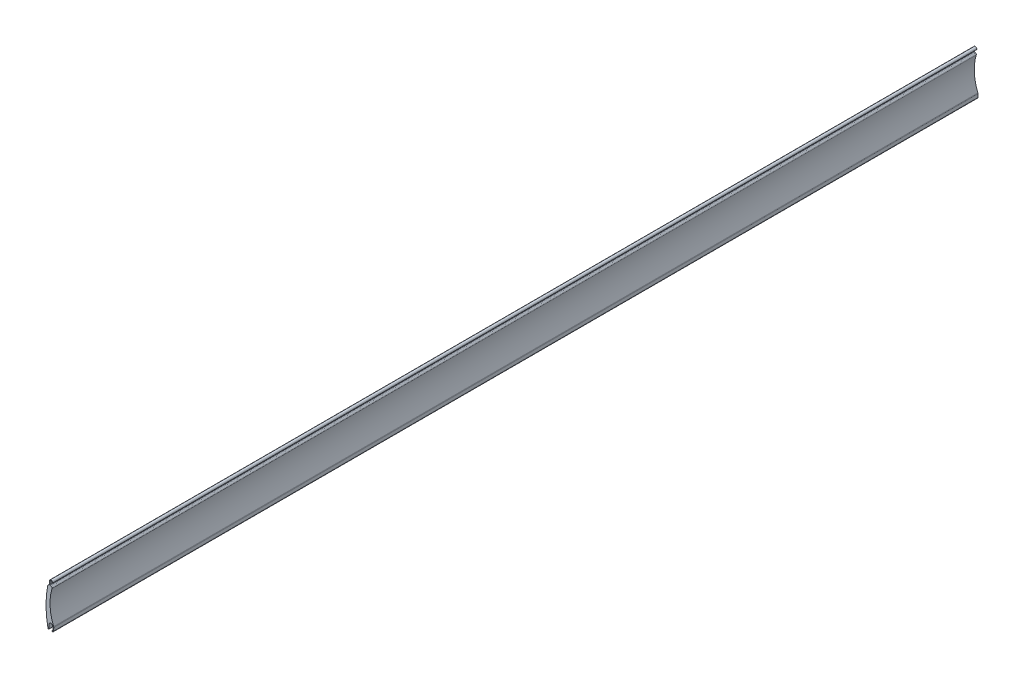
from build123d import *

# Parameters (mm, degrees)
BODY_DEPTH                      = 885
SCHNITT_LINEAR_AUSTRAGEN2_DEPTH = 885


with BuildPart() as part:
    # Model → Body (new body)
    with BuildSketch(Plane.XY):
        with BuildLine():
            Line((1.878084628, 39.104629182), (2.149753631, 39.265339178))
            ThreePointArc((2.149753631, 39.265339178), (1.179756728, 40.293308137), (0.151359725, 39.323765061))
            Line((0.151359725, 39.323765061), (0.072230593, 36.617684207))
            ThreePointArc((0.072230593, 36.617684207), (0.185489498, 36.248958877), (0.499809768, 36.025377312))
            Line((0.499809768, 36.025377312), (1.261518581, 35.79721719))
            ThreePointArc((1.261518581, 35.79721719), (2.002767255, 35.193636824), (2.100773109, 34.24276685))
            ThreePointArc((2.100773109, 34.24276685), (0.243973004, 18.756791477), (3.6673456, 3.540232734))
            ThreePointArc((3.6673456, 3.540232734), (3.762278433, 3.217871116), (3.78778584, 2.882791084))
            Line((3.78778584, 2.882791084), (3.698637797, -0.165904914))
            ThreePointArc((3.698637797, -0.165904914), (3.256166133, -1.000710488), (2.324510635, -1.157871399))
            Line((2.324510635, -1.157871399), (2.175621232, -1.113273313))
            ThreePointArc((2.175621232, -1.113273313), (1.997498531, -0.968129525), (1.974178859, -0.739545604))
            Line((1.974178859, -0.739545604), (0.400869285, -0.26828127))
            Line((0.400869285, -0.26828127), (-0.708129005, -0.492759369))
            ThreePointArc((-0.708129005, -0.492759369), (-1.196616048, -1.010909594), (-1.76840947, -0.586466985))
            ThreePointArc((-1.76840947, -0.586466985), (-3.655039198, 17.174334722), (-1.986171677, 34.956919747))
            ThreePointArc((-1.986171677, 34.956919747), (-1.847587365, 35.23826116), (-1.585988155, 35.411248024))
            Line((-1.585988155, 35.411248024), (-1.044699422, 35.590524224))
            ThreePointArc((-1.044699422, 35.590524224), (-0.684484453, 35.850559404), (-0.538564027, 36.270178693))
            Line((-0.538564027, 36.270178693), (-0.448759368, 39.341314215))
            ThreePointArc((-0.448759368, 39.341314215), (1.197302045, 40.893129938), (2.749873366, 39.247781189))
            ThreePointArc((2.749873366, 39.247781189), (2.372981432, 38.816883238), (1.878084628, 39.104629182))
        make_face()
    extrude(amount=-BODY_DEPTH)

    # Skizze3 → Schnitt-Linear austragen2 (cut)
    with BuildSketch(Plane.XY):
        with BuildLine():
            Line((-0.588130108, 3.611006063), (-0.708129005, -0.492759369))
            Line((-0.708129005, -0.492759369), (0.400869714, -0.268279835))
            Line((0.400869714, -0.268279835), (1.974178926, -0.739545381))
            ThreePointArc((1.974178926, -0.739545381), (2.119322659, -0.561422774), (2.347906465, -0.53810304))
            Line((2.347906465, -0.53810304), (2.496795914, -0.582700974))
            ThreePointArc((2.496795914, -0.582700974), (2.904733153, -0.513885986), (3.0984751, -0.148355754))
            Line((3.0984751, -0.148355754), (3.128422919, 0.875806051))
            ThreePointArc((3.128422919, 0.875806051), (2.924721832, 2.674341696), (2.225195598, 4.343739086))
            ThreePointArc((2.225195598, 4.343739086), (0.543823558, 5.032117471), (-0.588130108, 3.611006063))
        make_face()
    extrude(amount=-SCHNITT_LINEAR_AUSTRAGEN2_DEPTH, mode=Mode.SUBTRACT)


with BuildPart() as schnitt_linear_austragen2_kept_piece:
    # of the separate pieces the step leaves, the one the design keeps (schnitt_linear_austragen2_pieces_kept)
    add(part.part.solids().sort_by_distance((-1.986171677, 34.956919747, 0))[0])


solid = schnitt_linear_austragen2_kept_piece.part
